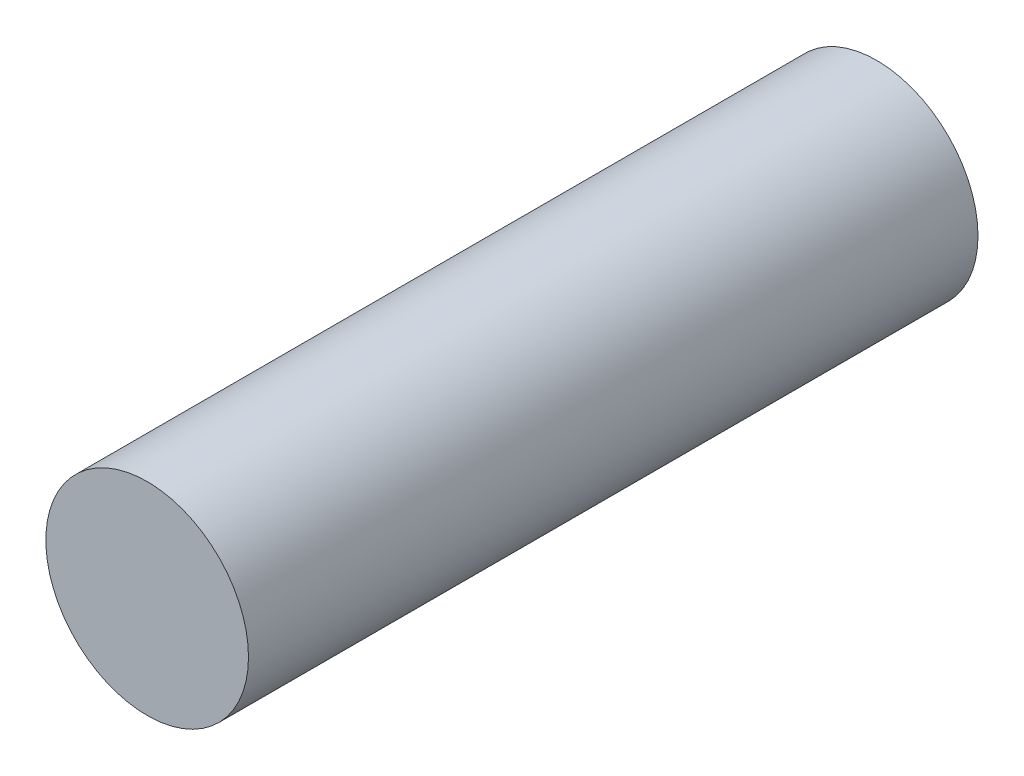
from build123d import *

# Parameters (mm, degrees)
SKETCH3_R           = 1.25
BOSS_EXTRUDE1_DEPTH = 9


with BuildPart() as part:
    # Sketch3 → Boss-Extrude1 (new body)
    with BuildSketch(Plane.XY):
        Circle(SKETCH3_R)
    extrude(amount=BOSS_EXTRUDE1_DEPTH)


solid = part.part
